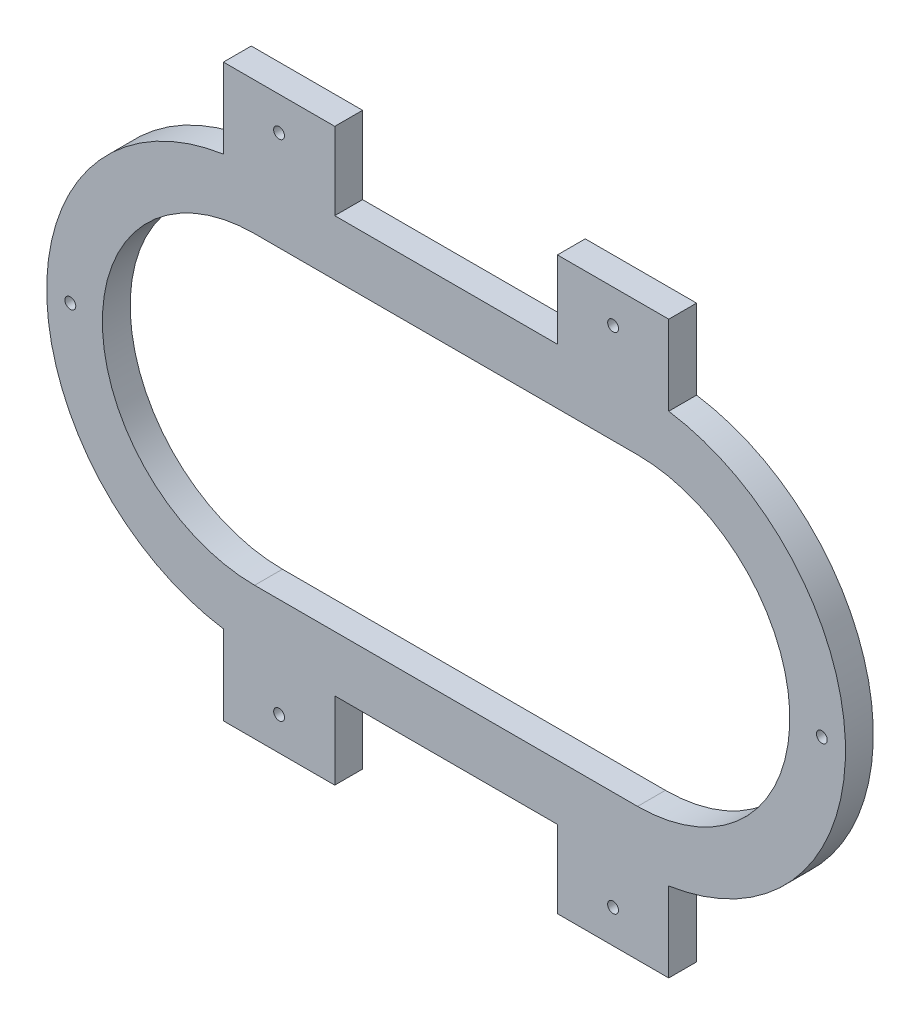
from build123d import *

# Parameters (mm, degrees)
SKETCH1_R           = 1.95
BOSS_EXTRUDE1_DEPTH = 10


with BuildPart() as part:
    # Sketch1 → Boss-Extrude1 (new body)
    with BuildSketch(Plane.XY):
        with BuildLine():
            ThreePointArc((-81.354892482, 80.223597026), (-144.854892482, 6.367994666), (-81.354892482, -67.487607695))
            Line((-81.354892482, -67.487607695), (-81.354892482, -96.132005334))
            Line((-81.354892482, -96.132005334), (-41.354892482, -96.132005334))
            Line((-41.354892482, -96.132005334), (-41.354892482, -68.332005334))
            Line((-41.354892482, -68.332005334), (38.645107518, -68.332005334))
            Line((38.645107518, -68.332005334), (38.645107518, -96.132005334))
            Line((38.645107518, -96.132005334), (78.645107518, -96.132005334))
            Line((78.645107518, -96.132005334), (78.645107518, -67.487607695))
            ThreePointArc((78.645107518, -67.487607695), (142.145107518, 6.367994666), (78.645107518, 80.223597026))
            Line((78.645107518, 80.223597026), (78.645107518, 108.867994666))
            Line((78.645107518, 108.867994666), (38.645107518, 108.867994666))
            Line((38.645107518, 108.867994666), (38.645107518, 81.067994666))
            Line((38.645107518, 81.067994666), (-41.354892482, 81.067994666))
            Line((-41.354892482, 81.067994666), (-41.354892482, 108.867994666))
            Line((-41.354892482, 108.867994666), (-81.354892482, 108.867994666))
            Line((-81.354892482, 108.867994666), (-81.354892482, 80.223597026))
        make_face()
        with Locations((-136.354892482, 6.367994666)):
            Circle(SKETCH1_R, mode=Mode.SUBTRACT)
        with Locations((133.645107518, 6.367994666)):
            Circle(SKETCH1_R, mode=Mode.SUBTRACT)
        with BuildLine():
            Line((-70.154892482, 61.067994666), (67.445107518, 61.067994666))
            ThreePointArc((67.445107518, 61.067994666), (122.145107518, 6.367994666), (67.445107518, -48.332005334))
            Line((67.445107518, -48.332005334), (-70.154892482, -48.332005334))
            ThreePointArc((-70.154892482, -48.332005334), (-124.854892482, 6.367994666), (-70.154892482, 61.067994666))
        make_face(mode=Mode.SUBTRACT)
        with Locations((-61.354892482, 96.867994666)):
            Circle(SKETCH1_R, mode=Mode.SUBTRACT)
        with Locations((58.645107518, 96.867994666)):
            Circle(SKETCH1_R, mode=Mode.SUBTRACT)
        with Locations((-61.354892482, -84.132005334)):
            Circle(SKETCH1_R, mode=Mode.SUBTRACT)
        with Locations((58.645107518, -84.132005334)):
            Circle(SKETCH1_R, mode=Mode.SUBTRACT)
    extrude(amount=BOSS_EXTRUDE1_DEPTH)


solid = part.part
